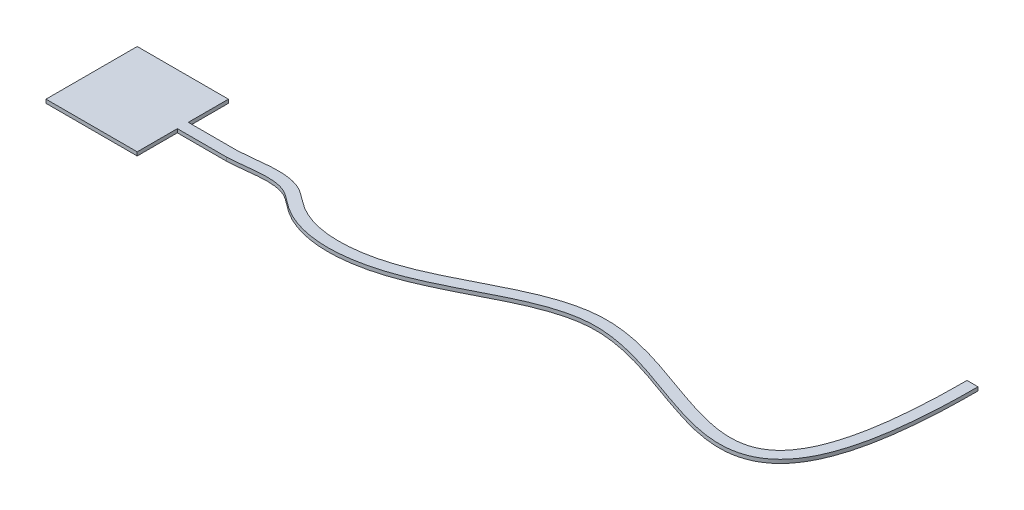
from build123d import *

# Parameters (mm, degrees)
SKETCH1_W           = 250
SKETCH1_H           = 250
BOSS_EXTRUDE1_DEPTH = 10
BOSS_EXTRUDE2_DEPTH = 10


with BuildPart() as part:
    # Sketch1 → Boss-Extrude1 (new body)
    with BuildSketch(Plane(origin=(0, 0, 0), x_dir=(1, 0, 0), z_dir=(0, 1, 0))):
        with Locations((-34.863945578, -8.503401361)):
            Rectangle(SKETCH1_W, SKETCH1_H)
    extrude(amount=BOSS_EXTRUDE1_DEPTH)

    # Sketch2 → Boss-Extrude2 (add)
    with BuildSketch(Plane(origin=(0, 10, 0), x_dir=(1, 0, 0), z_dir=(0, 1, 0))):
        with BuildLine():
            Line((90.136054422, 6.496598639), (90.136054422, -23.503401361))
            Line((90.136054422, -23.503401361), (224.598505459, -23.503401361))
            add(Edge.make_bspline(
                [(224.598505459, -23.503401361), (224.908041881, -23.492183957), (225.522573011, -23.469755843), (226.787755954, -23.419030542), (228.987501267, -23.320910585), (233.40655109, -23.085055285), (242.264505541, -22.472797073), (254.982003607, -21.278835694), (270.256335124, -19.590398787), (290.517505273, -17.321523661), (315.389033429, -15.043579724), (338.83263187, -14.989170703), (356.210386122, -17.029079702), (368.443241936, -19.743471808), (377.956332895, -23.124627909), (385.09893533, -26.546895641), (392.186511952, -30.607618288), (401.314719239, -36.911656985), (412.746876688, -45.744175229), (422.908935178, -53.526976903), (431.652275172, -59.573645884), (440.552908646, -65.22977971), (452.000971118, -71.649905562), (470.907542457, -80.549766229), (495.512333253, -89.206289485), (526.17191751, -95.955071742), (557.592937415, -99.387885295), (589.42834564, -99.815246681), (631.994680785, -96.775609842), (684.568038393, -86.900001163), (744.291054452, -67.567972255), (801.360344457, -43.196246405), (856.322445707, -16.106116551), (909.759621843, 11.427377068), (962.189603916, 37.173961731), (1014.079034849, 58.95052893), (1057.224494112, 72.042743509), (1091.937457899, 78.502786709), (1113.780859798, 80.677237651), (1131.410632154, 81.172379604), (1149.262535422, 80.859761819), (1171.925315403, 79.043284667), (1199.603786391, 74.84393677), (1237.016510646, 66.9224845), (1284.483938829, 53.380592531), (1341.784882225, 33.689885695), (1398.716497092, 13.006658154), (1454.654166489, -6.195028112), (1509.078364675, -21.407997598), (1561.599545262, -30.025516401), (1611.925721469, -29.177374728), (1651.432251575, -17.730008467), (1680.520552052, -0.642098504), (1707.513841642, 21.970468202), (1730.935887961, 53.090251417), (1750.605315766, 93.396640013), (1763.506927613, 128.508027783), (1774.548853207, 168.808622764), (1782.181655352, 206.993903293), (1787.325280511, 240.471222263), (1790.695000284, 267.085860216), (1793.5695443, 295.249059517), (1795.941110768, 325.002558916), (1797.491393219, 351.15693661), (1798.471684939, 372.917032875), (1799.075824096, 389.660315408), (1799.547759264, 406.832830642), (1799.886349196, 424.436314877), (1800.056424244, 439.479768153), (1800.124650573, 451.717901202), (1800.136054422, 457.945117946), (1800.136054422, 461.045215384)],
                knots=[-0.000148145, -0.000148145, -0.000148145, -0.000148145, 0.000340209, 0.000828562, 0.001805269, 0.003758684, 0.007665512, 0.01547917, 0.023292827, 0.031106484, 0.046733799, 0.062361114, 0.070174771, 0.077988429, 0.085802086, 0.089708915, 0.093615744, 0.101429401, 0.109243058, 0.117056716, 0.120963544, 0.124870373, 0.13268403, 0.140497688, 0.156125003, 0.171752317, 0.187379632, 0.203006947, 0.218634262, 0.249888891, 0.281143521, 0.31239815, 0.34365278, 0.374907409, 0.406162039, 0.437416668, 0.468671298, 0.484298613, 0.499925927, 0.507739585, 0.515553242, 0.531180557, 0.546807872, 0.562435187, 0.593689816, 0.624944446, 0.656199075, 0.687453705, 0.718708334, 0.749962964, 0.781217593, 0.812472223, 0.828099538, 0.843726852, 0.874981482, 0.890608797, 0.906236111, 0.921863426, 0.937490741, 0.945304398, 0.953118056, 0.960931713, 0.96874537, 0.976559028, 0.980465857, 0.984372685, 0.988279514, 0.992186343, 0.996093171, 0.998046586, 1, 1, 1, 1], degree=3))
            Line((1800.136054422, 461.045215384), (1785.136054422, 461.045215384))
            Line((1785.136054422, 461.045215384), (1770.136054422, 461.045215384))
            add(Edge.make_bspline(
                [(224.051368883, 6.496598639), (225.189875413, 6.539003331), (227.454963814, 6.637719663), (232.073765838, 6.891838046), (237.943470261, 7.305448654), (245.143318244, 7.929659796), (254.921612027, 8.895469645), (267.441580662, 10.282772582), (282.820235819, 12.001617522), (298.447355705, 13.531764745), (314.22776062, 14.62167275), (330.075530365, 15.008354902), (345.910588473, 14.411830884), (361.644202975, 12.532338785), (377.177361099, 9.037821567), (389.78631044, 4.518442102), (399.628616591, -0.264277531), (408.986196797, -5.698506542), (419.715016726, -13.200747967), (431.652203278, -22.448911881), (441.143802265, -29.681636042), (448.603557681, -34.806956402), (456.26832738, -39.652778946), (466.138186644, -45.156058587), (482.544732998, -52.835731126), (504.113585769, -60.384274332), (531.417966592, -66.354699559), (559.81779009, -69.421341068), (588.961891459, -69.779662127), (618.4793391, -67.639704319), (648.009037616, -63.224731085), (677.129152958, -56.772283871), (705.68296064, -48.513406819), (743.16034581, -35.429937844), (789.025767701, -15.829870507), (843.001247772, 10.777215981), (896.425833845, 38.304365027), (949.865718642, 64.544201594), (1003.939649778, 87.239895947), (1050.082709503, 101.249840131), (1087.92692482, 108.270788727), (1116.850459119, 111.13337229), (1146.239599288, 111.224713673), (1175.723261488, 108.82661584), (1205.295751798, 104.317384995), (1244.732352248, 95.941027532), (1293.896556919, 81.879284277), (1352.152588954, 61.842799785), (1409.069486988, 41.164893889), (1463.962991422, 22.340141929), (1516.044153786, 7.830017795), (1564.394141688, -0.003704514), (1607.996784316, 0.936566816), (1639.891427708, 10.320611499), (1663.145098574, 23.986750265), (1679.607518558, 37.7630102), (1695.124501001, 55.55949754), (1709.614245011, 77.862570288), (1722.92181288, 105.087756618), (1734.875968896, 137.585139369), (1745.317670421, 175.663478824), (1752.642652768, 212.28774748), (1757.61618396, 244.66470749), (1760.889389746, 270.521770886), (1763.69238344, 297.988890919), (1766.012530232, 327.101996501), (1767.533455038, 352.764649288), (1768.496776896, 374.154087984), (1769.091116739, 390.630171456), (1769.55587432, 407.545755729), (1769.889635792, 424.901999797), (1770.057439866, 439.747285483), (1770.124791044, 451.830930601), (1770.136054422, 457.982966399), (1770.136054422, 461.045215384)],
                knots=[0.000154285, 0.000154285, 0.000154285, 0.000154285, 0.002107109, 0.004059932, 0.00796558, 0.011871227, 0.015776874, 0.023588169, 0.031399464, 0.039210758, 0.047022053, 0.054833348, 0.062644642, 0.070455937, 0.078267232, 0.086078526, 0.089984174, 0.093889821, 0.101701115, 0.10951241, 0.117323705, 0.121229352, 0.125134999, 0.132946294, 0.140757589, 0.156380178, 0.172002767, 0.187625357, 0.203247946, 0.218870535, 0.234493124, 0.250115714, 0.265738303, 0.281360892, 0.312606071, 0.34385125, 0.375096428, 0.406341607, 0.437586785, 0.468831964, 0.484454553, 0.500077143, 0.515699732, 0.531322321, 0.54694491, 0.5625675, 0.593812678, 0.625057857, 0.656303035, 0.687548214, 0.718793393, 0.750038571, 0.78128375, 0.812528928, 0.828151518, 0.843774107, 0.859396696, 0.875019286, 0.890641875, 0.906264464, 0.921887054, 0.937509643, 0.945320937, 0.953132232, 0.960943527, 0.968754821, 0.976566116, 0.980471763, 0.984377411, 0.988283058, 0.992188705, 0.996094353, 0.998047176, 1, 1, 1, 1], degree=3))
            Line((224.051368883, 6.496598639), (90.136054422, 6.496598639))
        make_face()
    extrude(amount=-BOSS_EXTRUDE2_DEPTH)


solid = part.part
